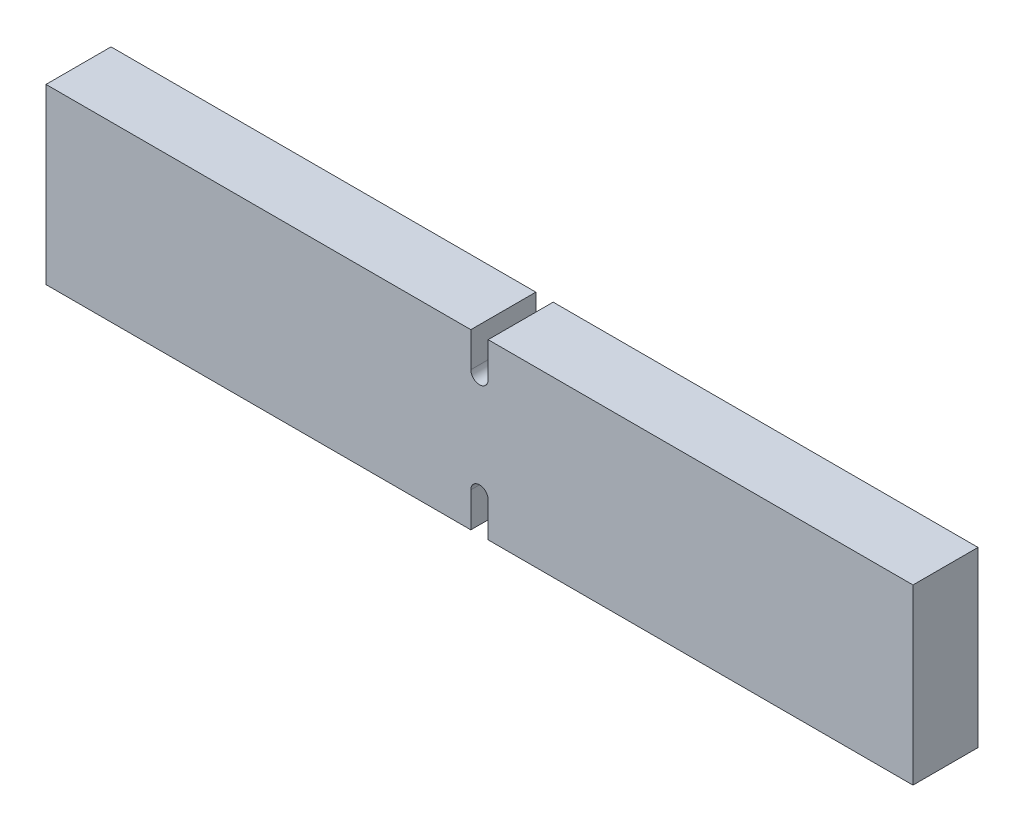
from build123d import *

# Parameters (mm, degrees)
SKETCH1_W                                = 200
SKETCH1_H                                = 40
RECTANGULAR_BAR_40_W_X_200_L_X_15D_DEPTH = 15
NOTCH_CUT_OUT_DEPTH                      = 15


with BuildPart() as part:
    # Sketch1 → Rectangular Bar (40 W x 200 L x 15D) (new body)
    with BuildSketch(Plane.XY):
        Rectangle(SKETCH1_W, SKETCH1_H)
    extrude(amount=RECTANGULAR_BAR_40_W_X_200_L_X_15D_DEPTH)

    # Notch → Notch cut out (cut)
    with BuildSketch(Plane.XY.offset(15)):
        with BuildLine():
            Line((2, 20), (2, 12))
            ThreePointArc((2, 12), (0, 10), (-2, 12))
            Line((-2, 12), (-2, 20))
            Line((-2, 20), (2, 20))
        make_face()
        with BuildLine():
            Line((-2, -20), (-2, -12))
            ThreePointArc((-2, -12), (0, -10), (2, -12))
            Line((2, -12), (2, -20))
            Line((2, -20), (-2, -20))
        make_face()
    extrude(amount=-NOTCH_CUT_OUT_DEPTH, mode=Mode.SUBTRACT)


solid = part.part
